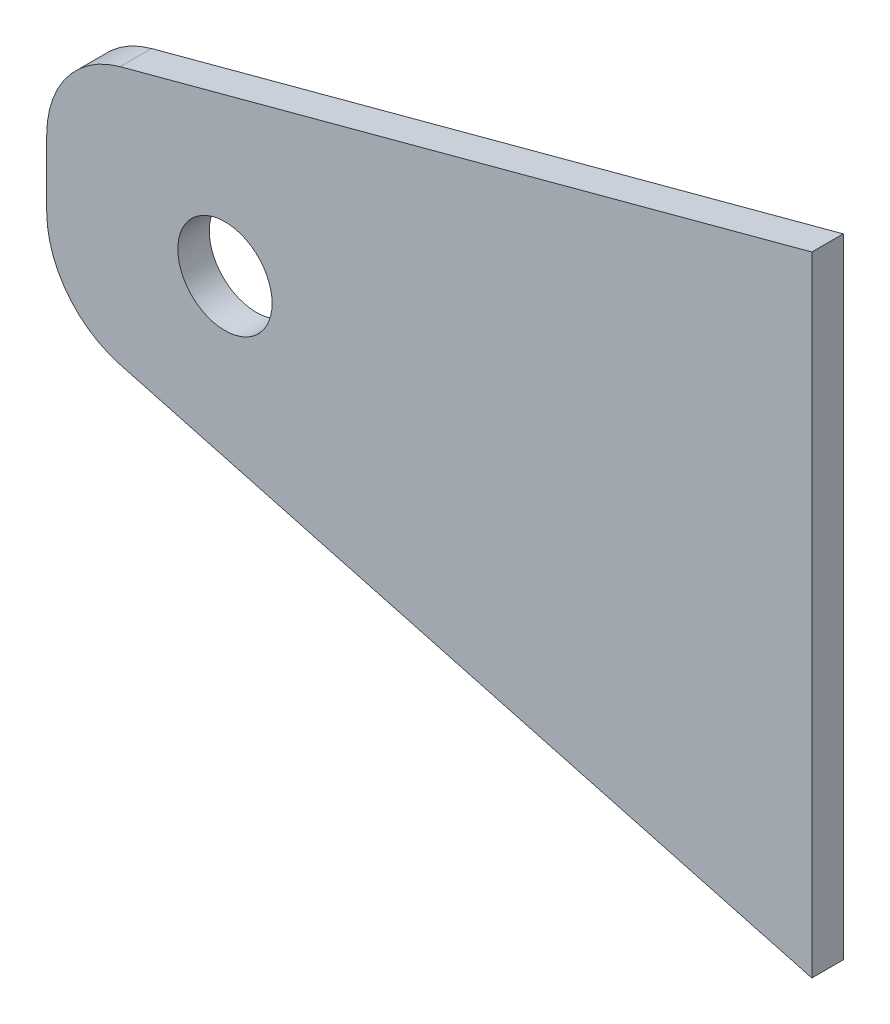
from build123d import *

# Parameters (mm, degrees)
SALIENTE_EXTRUIR1_DEPTH = 3.175
CROQUIS2_R              = 4.7625
CORTAR_EXTRUIR1_DEPTH   = 3.175
REDONDEO1_R             = 10


with BuildPart() as part:
    # Croquis1 → Saliente-Extruir1 (new body)
    with BuildSketch(Plane.XY):
        Polygon((0, 0), (0, 63.5), (-77.274066103, 42.794476392), (-77.274066103, 20.705523608), align=None)
    extrude(amount=SALIENTE_EXTRUIR1_DEPTH)

    # Croquis2 → Cortar-Extruir1 (cut)
    with BuildSketch(Plane.XY.offset(3.175)):
        with Locations((-59.274066103, 31.75)):
            Circle(CROQUIS2_R)
    extrude(amount=-CORTAR_EXTRUIR1_DEPTH, mode=Mode.SUBTRACT)

    # Redondeo1
    redondeo1_edges = [part.edges().sort_by_distance(p)[0] for p in [
        (-77.274066103, 20.705523608, 1.5875),
        (-77.274066103, 42.794476392, 1.5875),
    ]]
    fillet(redondeo1_edges, radius=REDONDEO1_R)


solid = part.part
